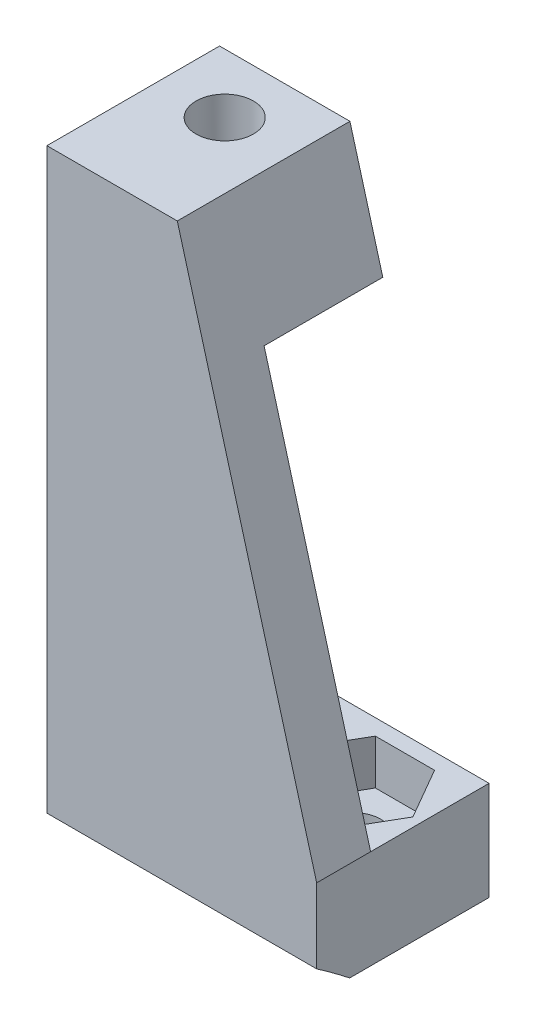
from build123d import *

# Parameters (mm, degrees)
BOSS_EXTRUDE1_DEPTH  = 15
CUT_EXTRUDE2_REACH   = 8.6
SKETCH3_R            = 1.595559434
CUT_EXTRUDE5_START   = -3.6
SKETCH3_6_R          = 1.595559434
CUT_EXTRUDE5_DEPTH   = 2.6
CUT_EXTRUDE3_REACH   = 5
SKETCH4_R            = 1.5
BOSS_EXTRUDE10_DEPTH = 2.5
CUT_EXTRUDE1_DEPTH   = 10.6


with BuildPart() as part:
    # Sketch1 → Boss-Extrude1 (new body)
    with BuildSketch(Plane.ZY.offset(20.222709888)):
        with BuildLine():
            Line((144.27017666, 37.109962519), (144.27017666, 13.209962519))
            Line((144.27017666, 13.209962519), (137.68267666, 13.209962519))
            Line((137.68267666, 13.209962519), (137.68267666, 10.209962519))
            Line((137.68267666, 10.209962519), (145.433552955, 10.209962519))
            ThreePointArc((145.433552955, 10.209962519), (146.341426982, 10.902339978), (147.27017666, 11.566452794))
            Line((147.27017666, 11.566452794), (147.27017666, 43.709962519))
            Line((147.27017666, 43.709962519), (137.67017666, 43.709962519))
            Line((137.67017666, 43.709962519), (137.67017666, 37.109962519))
            Line((137.67017666, 37.109962519), (144.27017666, 37.109962519))
        make_face()
    extrude(amount=-BOSS_EXTRUDE1_DEPTH)

    # Sketch3 → Cut-Extrude2 (cut, up to next)
    with BuildSketch(Plane.XZ.offset(-37.109962519), mode=Mode.PRIVATE) as cut_extrude2_sk1:
        with Locations((-16.635209888, 140.97017666)):
            Circle(SKETCH3_R)
    cut_extrude2_tool1 = extrude(cut_extrude2_sk1.sketch, amount=-CUT_EXTRUDE2_REACH, mode=Mode.PRIVATE) & part.part
    add(cut_extrude2_tool1.solids().sort_by_distance((-16.63521, 37.109963, 140.970177))[0], mode=Mode.SUBTRACT)

    # Sketch3_6 → Cut-Extrude5 (cut)
    with BuildSketch(Plane.XZ.offset(-37.109962519).offset(CUT_EXTRUDE5_START)):
        Polygon((-19.485209888, 139.324728393), (-16.635209888, 137.679280126), (-13.785209888, 139.324728393), (-13.785209888, 142.615624927), (-16.635209888, 144.261073195), (-19.485209888, 142.615624927), align=None)
        with Locations((-16.635209888, 140.97017666)):
            Circle(SKETCH3_6_R, mode=Mode.SUBTRACT)
        Polygon((-13.785209888, 139.324728393), (-16.635209888, 137.679280126), (-19.485209888, 139.324728393), (-19.485209888, 137.67017666), (-13.785209888, 137.67017666), align=None)
        with Locations((-16.635209888, 140.97017666)):
            Circle(SKETCH3_6_R)
    extrude(amount=CUT_EXTRUDE5_DEPTH, mode=Mode.SUBTRACT)

    # Sketch4 → Cut-Extrude3 (cut, up to next)
    with BuildSketch(Plane(origin=(0, 13.209962519, 0), x_dir=(1, 0, 0), z_dir=(0, 1, 0)), mode=Mode.PRIVATE) as cut_extrude3_sk1:
        with Locations((-16.431813353, -141.42017666)):
            Circle(SKETCH4_R)
    cut_extrude3_tool1 = extrude(cut_extrude3_sk1.sketch, amount=-CUT_EXTRUDE3_REACH, mode=Mode.PRIVATE) & part.part
    add(cut_extrude3_tool1.solids().sort_by_distance((-16.431813, 13.209963, 141.420177))[0], mode=Mode.SUBTRACT)
    # Sketch4 → Cut-Extrude3 (cut, up to next)
    with BuildSketch(Plane(origin=(0, 13.209962519, 0), x_dir=(1, 0, 0), z_dir=(0, 1, 0)), mode=Mode.PRIVATE) as cut_extrude3_sk2:
        with Locations((-9.013606422, -141.42017666)):
            Circle(SKETCH4_R)
    cut_extrude3_tool2 = extrude(cut_extrude3_sk2.sketch, amount=-CUT_EXTRUDE3_REACH, mode=Mode.PRIVATE) & part.part
    add(cut_extrude3_tool2.solids().sort_by_distance((-9.013606, 13.209963, 141.420177))[0], mode=Mode.SUBTRACT)

    # Sketch11 → Boss-Extrude10 (add)
    with BuildSketch(Plane(origin=(0, 13.209962519, 0), x_dir=(1, 0, 0), z_dir=(0, 1, 0))):
        Polygon((-18.077261621, -144.27017666), (-19.722709888, -141.42017666), (-18.077261621, -138.57017666), (-14.786365086, -138.57017666), (-13.140916819, -141.42017666), (-14.786365086, -144.27017666), (-10.659054689, -144.27017666), (-12.304502957, -141.42017666), (-10.659054689, -138.57017666), (-7.368158155, -138.57017666), (-5.722709888, -141.42017666), (-7.368158155, -144.27017666), (-5.222709888, -144.27017666), (-5.222709888, -137.68267666), (-20.222709888, -137.68267666), (-20.222709888, -144.27017666), align=None)
    extrude(amount=BOSS_EXTRUDE10_DEPTH)

    # Sketch2 → Cut-Extrude1 (cut, through all)
    with BuildSketch(Plane.XY.offset(147.27017666)):
        Polygon((-12.972709888, 43.709962519), (-5.222709888, 15.709962519), (-5.222709888, 43.709962519), align=None)
    extrude(amount=-CUT_EXTRUDE1_DEPTH, mode=Mode.SUBTRACT)


solid = part.part
